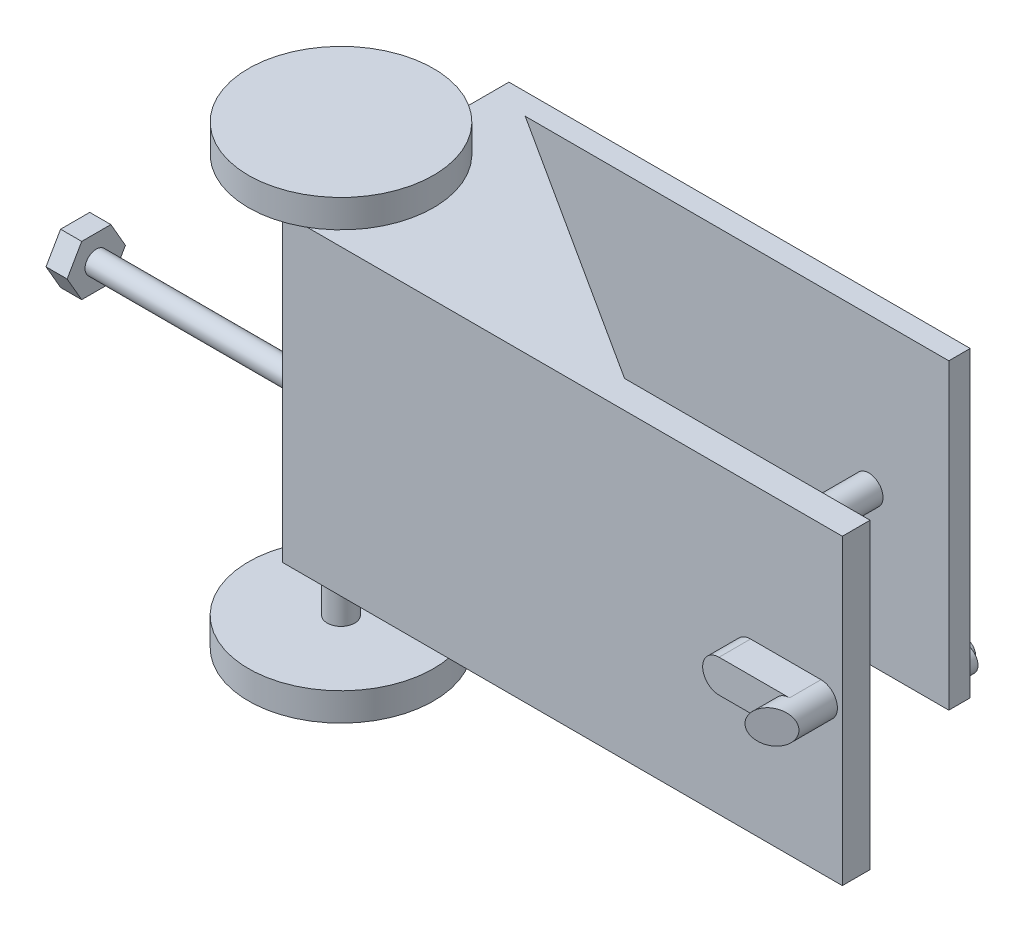
from build123d import *

# Parameters (mm, degrees)
ESQUISSE1_W              = 161.459359481
ESQUISSE1_H              = 87.247834422
BOSS_EXTRU_1_DEPTH       = 8
BOSS_EXTRU_4_DEPTH       = 8
BOSS_EXTRU_5_DEPTH       = 79.247834422
ESQUISSE10_W             = 66.113003305
ESQUISSE10_H             = 74.491262117
ENL_V_MAT_EXTRU_2_DEPTH  = 96
ESQUISSE13_W             = 6.170645308
ESQUISSE13_H             = 87.247834422
BOSS_EXTRU_6_DEPTH       = 133
ESQUISSE16_R             = 4.09250964
BOSS_EXTRU_8_DEPTH       = 61.090356673
BOSS_EXTRU_9_DEPTH       = 4.090356673
ESQUISSE20_R             = 2.950247855
BOSS_EXTRU_11_DEPTH      = 2.090356673
ESQUISSE22_R             = 2.950247855
BOSS_EXTRU_12_DEPTH      = 2.090356673
ESQUISSE23_R             = 3.399065534
BOSS_EXTRU_13_DEPTH      = 4.090356673
ESQUISSE24_R             = 3.959119082
BOSS_EXTRU_14_DEPTH      = 15.090356673
BOSS_EXTRU_14_DEPTH_BACK = 100
ESQUISSE25_R             = 26.684784867
BOSS_EXTRU_15_DEPTH      = 8.090356673
ESQUISSE26_R             = 26.684784865
BOSS_EXTRU_16_DEPTH      = 8.090356673
BOSS_EXTRU_17_DEPTH      = 9.090356673
ESQUISSE28_R             = 3.241314471
BOLT_DEPTH               = 58.090356673
ESQUISSE29_W             = 15.037271033
ESQUISSE29_H             = 95.331740118
ENL_V_MAT_EXTRU_4_DEPTH  = 9.090356673
BOLT_2_DEPTH             = 6.090356673
ESQUISSE31_R             = 4.734333437
BOSS_EXTRU_20_DEPTH      = 8.090356673
ENL_V_MAT_EXTRU_5_DEPTH  = 11.090356673
ESQUISSE34_W             = 0.427403847
ESQUISSE34_H             = 3.480288462
ESQUISSE34_W_2           = 0.427403846
ESQUISSE34_H_2           = 4.884615385
ENL_V_MAT_EXTRU_6_DEPTH  = 1.090356673


with BuildPart() as part:
    # Esquisse1 → Boss.-Extru.1 (new body)
    with BuildSketch(Plane.XY):
        with Locations((81.722874728, 43.623917211)):
            Rectangle(ESQUISSE1_W, ESQUISSE1_H)
    extrude(amount=BOSS_EXTRU_1_DEPTH)

    # Esquisse8 → Boss.-Extru.4 (add)
    with BuildSketch(Plane(origin=(0, 87.247834422, 0), x_dir=(1, 0, 0), z_dir=(0, 1, 0))):
        Polygon((0.993194987, 58.123224096), (0.993194987, 0), (91.655263297, 0), align=None)
    extrude(amount=-BOSS_EXTRU_4_DEPTH)

    # Esquisse9 → Boss.-Extru.5 (add)
    with BuildSketch(Plane(origin=(0, 79.247834422, 0), x_dir=(-1, 0, 0), z_dir=(0, -1, 0))):
        Polygon((-0.993194987, 58.123224096), (-91.655263297, 0), (-0.993194987, 0), align=None)
    extrude(amount=BOSS_EXTRU_5_DEPTH)

    # Esquisse10 → Enlèv. mat.-Extru.2 (cut)
    with BuildSketch(Plane.ZY.offset(-0.993194987)):
        with Locations((-33.027552153, 43.69715526)):
            Rectangle(ESQUISSE10_W, ESQUISSE10_H)
    extrude(amount=-ENL_V_MAT_EXTRU_2_DEPTH, mode=Mode.SUBTRACT)

    # Esquisse13 → Boss.-Extru.6 (add)
    with BuildSketch(Plane.ZY.offset(-0.993194987)):
        with Locations((-54.244008063, 43.623917211)):
            Rectangle(ESQUISSE13_W, ESQUISSE13_H)
    extrude(amount=-BOSS_EXTRU_6_DEPTH)

    # Esquisse16 → Boss.-Extru.8 (add)
    with BuildSketch(Plane(origin=(0, 0, -57.329330717), x_dir=(-1, 0, 0), z_dir=(0, 0, -1))):
        with Locations((-110.923599868, 43.623917211)):
            Circle(ESQUISSE16_R)
    extrude(amount=-BOSS_EXTRU_8_DEPTH)

    # Esquisse18 → Boss.-Extru.9 (add)
    with BuildSketch(Plane(origin=(0, 0, -57.329330717), x_dir=(-1, 0, 0), z_dir=(0, 0, -1))):
        with BuildLine():
            Line((-128.571488185, 8.728625509), (-108.086880087, 8.728625509))
            ThreePointArc((-108.086880087, 8.728625509), (-104.513983326, 5.155728748), (-108.086880087, 1.582831987))
            Line((-108.086880087, 1.582831987), (-128.571488185, 1.582831987))
            ThreePointArc((-128.571488185, 1.582831987), (-132.144384946, 5.155728748), (-128.571488185, 8.728625509))
        make_face()
    extrude(amount=BOSS_EXTRU_9_DEPTH)

    # Esquisse20 → Boss.-Extru.11 (add)
    with BuildSketch(Plane(origin=(0, 0, -61.41968739), x_dir=(-1, 0, 0), z_dir=(0, 0, -1))):
        with Locations((-126.423545035, 5.155728748)):
            Circle(ESQUISSE20_R)
    extrude(amount=BOSS_EXTRU_11_DEPTH)

    # Esquisse22 → Boss.-Extru.12 (add)
    with BuildSketch(Plane(origin=(0, 0, -61.41968739), x_dir=(-1, 0, 0), z_dir=(0, 0, -1))):
        with Locations((-119.402690218, 5.155728748)):
            Circle(ESQUISSE22_R)
    extrude(amount=BOSS_EXTRU_12_DEPTH)

    # Esquisse23 → Boss.-Extru.13 (add)
    with BuildSketch(Plane(origin=(0, 0, -61.41968739), x_dir=(-1, 0, 0), z_dir=(0, 0, -1))):
        with Locations((-109.574754959, 5.155728748)):
            Circle(ESQUISSE23_R)
    extrude(amount=BOSS_EXTRU_13_DEPTH)

    # Esquisse24 → Boss.-Extru.14 (add, two sides)
    with BuildSketch(Plane(origin=(0, 87.247834422, 0), x_dir=(1, 0, 0), z_dir=(0, 1, 0))) as boss_extru_14_sk:
        with Locations(Location((9.899824308, 0, 0), (0, 0, 270))):
            Circle(ESQUISSE24_R)
    extrude(amount=BOSS_EXTRU_14_DEPTH)
    extrude(boss_extru_14_sk.sketch, amount=-BOSS_EXTRU_14_DEPTH_BACK)

    # Esquisse25 → Boss.-Extru.15 (add)
    with BuildSketch(Plane(origin=(0, 102.338191096, 0), x_dir=(1, 0, 0), z_dir=(0, 1, 0))):
        with Locations(Location((9.899824308, 0, 0), (0, 0, 270))):
            Circle(ESQUISSE25_R)
    extrude(amount=BOSS_EXTRU_15_DEPTH)

    # Esquisse26 → Boss.-Extru.16 (add)
    with BuildSketch(Plane(origin=(0, -12.752165578, 0), x_dir=(-1, 0, 0), z_dir=(0, -1, 0))):
        with Locations(Location((-9.899824308, 0, 0), (0, 0, 270))):
            Circle(ESQUISSE26_R)
    extrude(amount=BOSS_EXTRU_16_DEPTH)

    # Esquisse27 → Boss.-Extru.17 (add)
    with BuildSketch(Plane.XY.offset(8)):
        with BuildLine():
            Line((156.30087893, 38.889583774), (135.997136687, 38.889583774))
            ThreePointArc((135.997136687, 38.889583774), (131.26280325, 43.623917211), (135.997136687, 48.358250648))
            Line((135.997136687, 48.358250648), (156.30087893, 48.358250648))
            ThreePointArc((156.30087893, 48.358250648), (161.035212367, 43.623917211), (156.30087893, 38.889583774))
        make_face()
    extrude(amount=BOSS_EXTRU_17_DEPTH)

    # Esquisse28 → bolt (add)
    with BuildSketch(Plane.ZY.offset(-0.993194987)):
        with Locations(Location((3.562327103, 43.697155259, 0), (0, 0, 180))):
            Circle(ESQUISSE28_R)
    extrude(amount=BOLT_DEPTH)

    # Esquisse29 → Enlèv. mat.-Extru.4 (cut)
    with BuildSketch(Plane(origin=(0, 0, -57.329330717), x_dir=(-1, 0, 0), z_dir=(0, 0, -1))):
        with Locations((-8.438121195, 39.581964363)):
            Rectangle(ESQUISSE29_W, ESQUISSE29_H)
    extrude(amount=ENL_V_MAT_EXTRU_4_DEPTH, mode=Mode.SUBTRACT)

    # Esquisse30 → bolt 2 (add)
    with BuildSketch(Plane.ZY.offset(57.097161686)):
        Polygon((11.970343142, 43.697155259), (7.766335123, 50.978710744), (-0.641680916, 50.978710744), (-4.845688936, 43.697155259), (-0.641680916, 36.415599774), (7.766335123, 36.415599774), align=None)
    extrude(amount=BOLT_2_DEPTH)

    # Esquisse31 → Boss.-Extru.20 (add)
    with BuildSketch(Plane.XY.offset(17.090356673)):
        with Locations(Location((156.30087893, 43.623917211, 0), (0, 0, 90))):
            Circle(ESQUISSE31_R)
    extrude(amount=BOSS_EXTRU_20_DEPTH)

    # Esquisse32 → Enlèv. mat.-Extru.5 (cut)
    with BuildSketch(Plane(origin=(0, 48.358250648, 0), x_dir=(1, 0, 0), z_dir=(0, 1, 0))):
        Polygon((151.566545494, -25.180713347), (161.035212367, -19.096120647), (164.647293985, -24.717137409), (155.178627112, -30.801730109), align=None)
    extrude(amount=-ENL_V_MAT_EXTRU_5_DEPTH, mode=Mode.SUBTRACT)

    # Esquisse34 → Enlèv. mat.-Extru.6 (cut)
    with BuildSketch(Plane(origin=(0, 0, -57.329330717), x_dir=(-1, 0, 0), z_dir=(0, 0, -1))):
        with BuildLine():
            Line((-35.621382075, 83.377609007), (-35.99536044, 83.091401074))
            add(Edge.make_bspline(
                [(-35.99536044, 83.091401074), (-36.022038452, 83.123195483), (-36.0750348, 83.186355644), (-36.160296072, 83.275046381), (-36.24915295, 83.358138754), (-36.341571469, 83.436028598), (-36.439215128, 83.505992125), (-36.539718572, 83.571675305), (-36.644763055, 83.630550334), (-36.790021665, 83.701937469), (-36.980042487, 83.776431344), (-37.219249036, 83.838892526), (-37.468955209, 83.878654198), (-37.639313372, 83.882960643), (-37.725964406, 83.885151074)],
                knots=[0, 0, 0, 0, 0.757959112, 1.505699292, 2.245454638, 2.979532153, 3.711538275, 4.438200793, 5.171680507, 5.909471876, 7.393775596, 8.890124382, 10.418191784, 12, 12, 12, 12], degree=3))
            add(Edge.make_bspline(
                [(-37.725964406, 83.885151074), (-37.773702753, 83.884601397), (-37.868736389, 83.883507143), (-38.009772348, 83.869071155), (-38.14817475, 83.848781258), (-38.283853566, 83.818675015), (-38.416636092, 83.780612273), (-38.547390396, 83.735129834), (-38.674223391, 83.678857713), (-38.798889636, 83.616661831), (-38.918332063, 83.546411629), (-39.031346253, 83.469785247), (-39.137520024, 83.387640155), (-39.236937364, 83.299668471), (-39.329699908, 83.206266375), (-39.415135498, 83.106438467), (-39.492948503, 83.000503902), (-39.564681312, 82.889859587), (-39.628924353, 82.774827806), (-39.682713224, 82.6549828), (-39.730345194, 82.532376859), (-39.76803595, 82.405624744), (-39.797868953, 82.275618338), (-39.81845338, 82.14200873), (-39.832725193, 82.005075044), (-39.833814005, 81.912261658), (-39.834362844, 81.865477096)],
                knots=[0, 0, 0, 0, 1.054917814, 2.100044995, 3.131103042, 4.146048494, 5.169673617, 6.183595914, 7.203665975, 8.234915748, 9.262203917, 10.264457458, 11.251630812, 12.227803204, 13.197192746, 14.159520551, 15.12972552, 16.100847026, 17.073214652, 18.039054194, 19.002613845, 19.979014051, 20.95965708, 21.949030935, 22.966165397, 24, 24, 24, 24], degree=3))
            add(Edge.make_bspline(
                [(-39.834362844, 81.865477096), (-39.832645869, 81.79508555), (-39.829274816, 81.656881086), (-39.799273333, 81.454446791), (-39.753682476, 81.260516874), (-39.685353423, 81.076303589), (-39.601099287, 80.89953543), (-39.494636169, 80.733203276), (-39.371332952, 80.574793594), (-39.22944526, 80.428050154), (-39.073771632, 80.294001121), (-38.906746795, 80.175958365), (-38.728786746, 80.077558472), (-38.541856403, 79.995676201), (-38.344517298, 79.932734011), (-38.137124299, 79.888423543), (-37.920128477, 79.859519005), (-37.771852258, 79.856751736), (-37.696389587, 79.855343382)],
                knots=[0, 0, 0, 0, 1.029171465, 2.020641659, 2.987623507, 3.938342917, 4.889210282, 5.84687017, 6.821220943, 7.821438502, 8.827599549, 9.822697543, 10.807740252, 11.797342354, 12.80366471, 13.83203677, 14.896651826, 16, 16, 16, 16], degree=3))
            add(Edge.make_bspline(
                [(-37.696389587, 79.855343382), (-37.613246285, 79.857641329), (-37.449600377, 79.862164238), (-37.209613884, 79.90048093), (-36.979876646, 79.962608311), (-36.760376305, 80.049555127), (-36.551731662, 80.162583251), (-36.353616206, 80.299604291), (-36.165862712, 80.46192163), (-36.052962503, 80.585859743), (-35.99536044, 80.649093382)],
                knots=[0, 0, 0, 0, 1.028121516, 2.023589091, 2.998037872, 3.967518031, 4.937445131, 5.927275754, 6.942489185, 8, 8, 8, 8], degree=3))
            Line((-35.99536044, 80.649093382), (-35.621382075, 80.365747529))
            add(Edge.make_bspline(
                [(-35.621382075, 80.365747529), (-35.651478503, 80.326914849), (-35.711527199, 80.249435497), (-35.808761143, 80.140208635), (-35.911192037, 80.037469215), (-36.0195807, 79.942045559), (-36.132680266, 79.852028233), (-36.25252152, 79.76997467), (-36.377529025, 79.694739574), (-36.507279226, 79.625850794), (-36.641634267, 79.564731254), (-36.780433159, 79.512406663), (-36.923077621, 79.467333153), (-37.069574173, 79.430251053), (-37.220226685, 79.401307186), (-37.374491509, 79.381958271), (-37.532701589, 79.368702309), (-37.639437952, 79.367494109), (-37.693527507, 79.366881844)],
                knots=[0, 0, 0, 0, 0.986787822, 1.968848986, 2.935600012, 3.899624008, 4.868462664, 5.837806735, 6.815139263, 7.798259679, 8.787526145, 9.778297419, 10.776456485, 11.791383307, 12.812564526, 13.85620153, 14.913611965, 16, 16, 16, 16], degree=3))
            add(Edge.make_bspline(
                [(-37.693527507, 79.366881844), (-37.744749783, 79.367238341), (-37.84603549, 79.367943269), (-37.995576291, 79.379362611), (-38.141158542, 79.394942432), (-38.282366158, 79.418401325), (-38.419969717, 79.446084159), (-38.552721798, 79.483192547), (-38.681928709, 79.524761235), (-38.807071344, 79.573617663), (-38.92825615, 79.628748611), (-39.045092265, 79.69105784), (-39.157525953, 79.760021377), (-39.266662615, 79.834119088), (-39.370890041, 79.915731059), (-39.471111446, 80.003723872), (-39.567888815, 80.097800951), (-39.627763897, 80.165639162), (-39.657867952, 80.199746928)],
                knots=[0, 0, 0, 0, 1.114604814, 2.203992996, 3.262667896, 4.300477797, 5.318619304, 6.316056647, 7.298880507, 8.271930387, 9.238335007, 10.195173496, 11.151986948, 12.108099108, 13.064862484, 14.031167946, 15.010108607, 16, 16, 16, 16], degree=3))
            add(Edge.make_bspline(
                [(-39.657867952, 80.199746928), (-39.706085738, 80.258994045), (-39.801939184, 80.376772998), (-39.924574489, 80.567662137), (-40.029550269, 80.766963521), (-40.114426076, 80.97572421), (-40.180778223, 81.193475762), (-40.226744778, 81.420327944), (-40.25661464, 81.656068894), (-40.260030426, 81.816411095), (-40.26176669, 81.897913995)],
                knots=[0, 0, 0, 0, 0.994628077, 1.977248131, 2.950237994, 3.925870899, 4.908910175, 5.911660606, 6.938484602, 8, 8, 8, 8], degree=3))
            add(Edge.make_bspline(
                [(-40.26176669, 81.897913995), (-40.259650516, 81.98357838), (-40.255487076, 82.152117709), (-40.220114225, 82.399460124), (-40.163210792, 82.636430421), (-40.082388597, 82.86258623), (-39.97991953, 83.079117076), (-39.853336887, 83.284368858), (-39.70411124, 83.479654218), (-39.533412943, 83.662010004), (-39.346223104, 83.828751052), (-39.14576429, 83.975444494), (-38.932428855, 84.097524399), (-38.708567064, 84.199572749), (-38.472502619, 84.278010393), (-38.224739177, 84.332919551), (-37.965742297, 84.36709677), (-37.789036639, 84.371417321), (-37.699251666, 84.373612613)],
                knots=[0, 0, 0, 0, 1.032925535, 2.032216505, 3.007276963, 3.968222605, 4.92396291, 5.891752235, 6.871517503, 7.883894988, 8.900124299, 9.891468569, 10.874487609, 11.85992873, 12.854644235, 13.869047385, 14.917252991, 16, 16, 16, 16], degree=3))
            add(Edge.make_bspline(
                [(-37.699251666, 84.373612613), (-37.64453126, 84.37295656), (-37.536217726, 84.371657971), (-37.375990009, 84.35899497), (-37.219994557, 84.337885385), (-37.0681239, 84.309152447), (-36.919639197, 84.27349177), (-36.775675298, 84.227036579), (-36.635387442, 84.173919013), (-36.499660399, 84.112743386), (-36.369145379, 84.04407257), (-36.243883031, 83.968667739), (-36.124868348, 83.886622375), (-36.01126388, 83.798634269), (-35.904970035, 83.702841943), (-35.802968881, 83.601880215), (-35.708724342, 83.492840975), (-35.650549459, 83.416089976), (-35.621382075, 83.377609007)],
                knots=[0, 0, 0, 0, 1.096760587, 2.17092713, 3.219439832, 4.250915756, 5.268269357, 6.278326846, 7.281116186, 8.274029601, 9.260640565, 10.235837813, 11.203064059, 12.156899882, 13.114053108, 14.069676657, 15.032185724, 16, 16, 16, 16], degree=3))
        make_face()
        with BuildLine():
            Line((-31.225228229, 82.96928569), (-31.225228229, 79.488997228))
            Line((-31.225228229, 79.488997228), (-31.652632075, 79.488997228))
            Line((-31.652632075, 79.488997228), (-31.652632075, 80.090987913))
            add(Edge.make_bspline(
                [(-31.652632075, 80.090987913), (-31.700826929, 80.036505466), (-31.794879793, 79.930182284), (-31.951962172, 79.791277614), (-32.1184703, 79.676462826), (-32.293596026, 79.583730263), (-32.477181207, 79.5140725), (-32.668818883, 79.464561334), (-32.868587226, 79.432729008), (-33.005002038, 79.42955035), (-33.074131474, 79.427939536)],
                knots=[0, 0, 0, 0, 1.074387032, 2.096679803, 3.090159297, 4.057316773, 5.018401886, 5.985159533, 6.978961417, 8, 8, 8, 8], degree=3))
            add(Edge.make_bspline(
                [(-33.074131474, 79.427939536), (-33.135592154, 79.429608278), (-33.256795336, 79.432899112), (-33.435088473, 79.458429246), (-33.606663998, 79.499428414), (-33.771684042, 79.556443553), (-33.929080783, 79.632073171), (-34.080201843, 79.722616797), (-34.224264327, 79.830440927), (-34.359072386, 79.953705351), (-34.483213072, 80.087592816), (-34.592153589, 80.230393721), (-34.682985459, 80.38149057), (-34.75894064, 80.538970326), (-34.81744638, 80.70404527), (-34.858231932, 80.876144559), (-34.883732326, 81.055064708), (-34.887021799, 81.176902417), (-34.888689767, 81.238681723)],
                knots=[0, 0, 0, 0, 1.033919861, 2.038935746, 3.024066025, 3.998881131, 4.97069526, 5.957263378, 6.95902576, 7.993208707, 9.027059324, 10.027763471, 11.009749337, 11.988697705, 12.965288445, 13.950418724, 14.960734635, 16, 16, 16, 16], degree=3))
            add(Edge.make_bspline(
                [(-34.888689767, 81.238681723), (-34.886984831, 81.29918412), (-34.883614264, 81.418794094), (-34.858504704, 81.594705465), (-34.816280368, 81.764139242), (-34.757024189, 81.926549939), (-34.681039243, 82.082134079), (-34.588608525, 82.231001699), (-34.479725359, 82.373562915), (-34.354196191, 82.506465548), (-34.218213521, 82.629230027), (-34.072741284, 82.735922335), (-33.921398176, 82.828065619), (-33.761836723, 82.901072671), (-33.596418626, 82.960140059), (-33.423671259, 83.001006348), (-33.244313361, 83.025087346), (-33.12254237, 83.028574536), (-33.060775104, 83.030343382)],
                knots=[0, 0, 0, 0, 1.020392517, 2.01726096, 2.990465484, 3.961182959, 4.928053699, 5.906110375, 6.912531644, 7.948652711, 8.985773172, 9.998621852, 10.987621588, 11.969261332, 12.953316658, 13.946091881, 14.958173133, 16, 16, 16, 16], degree=3))
            add(Edge.make_bspline(
                [(-33.060775104, 83.030343382), (-32.98974601, 83.028387013), (-32.850461309, 83.024550666), (-32.646724268, 82.992624597), (-32.453986603, 82.938687969), (-32.270760503, 82.865321659), (-32.097703926, 82.76782821), (-31.936455222, 82.644846906), (-31.785326833, 82.497153362), (-31.69772365, 82.383710007), (-31.652632075, 82.325317841)],
                knots=[0, 0, 0, 0, 1.038897134, 2.037228247, 3.008116434, 3.962042015, 4.918381754, 5.904844433, 6.921570401, 8, 8, 8, 8], degree=3))
            Line((-31.652632075, 82.325317841), (-31.652632075, 82.96928569))
            Line((-31.652632075, 82.96928569), (-31.225228229, 82.96928569))
        make_face()
        with BuildLine():
            add(Edge.make_bspline(
                [(-33.055050945, 82.602939536), (-33.11752724, 82.600716622), (-33.24084551, 82.596328943), (-33.421880385, 82.562075008), (-33.595117566, 82.505082042), (-33.759690617, 82.427137741), (-33.912999869, 82.32912721), (-34.050015185, 82.210579899), (-34.171857218, 82.074730248), (-34.274330249, 81.922191305), (-34.357865175, 81.758663259), (-34.416603172, 81.587724292), (-34.455341684, 81.412457519), (-34.459299349, 81.293581864), (-34.461285921, 81.233911591)],
                knots=[0, 0, 0, 0, 1.031046209, 2.035121221, 3.029706178, 4.034933723, 5.034054252, 6.02443088, 7.017295772, 8.038157696, 9.050218397, 10.03989886, 11.016116709, 12, 12, 12, 12], degree=3))
            add(Edge.make_bspline(
                [(-34.461285921, 81.233911591), (-34.458748334, 81.17459791), (-34.453683106, 81.056203036), (-34.417283054, 80.880697323), (-34.35621437, 80.709718073), (-34.27288142, 80.544716506), (-34.168532834, 80.391521713), (-34.047580775, 80.253082474), (-33.90885557, 80.134034142), (-33.755193498, 80.034378729), (-33.59108051, 79.953875442), (-33.418495768, 79.897860768), (-33.24068356, 79.861696002), (-33.11978092, 79.857471696), (-33.058867051, 79.855343382)],
                knots=[0, 0, 0, 0, 0.979072187, 1.954306742, 2.945804271, 3.96968567, 4.997920485, 5.998718438, 6.996577872, 8.005894225, 9.015743152, 10.005417472, 10.995077863, 12, 12, 12, 12], degree=3))
            add(Edge.make_bspline(
                [(-33.058867051, 79.855343382), (-32.997027345, 79.857602119), (-32.874034304, 79.862094522), (-32.692462348, 79.896495101), (-32.516256702, 79.953330501), (-32.347817652, 80.03211467), (-32.190905345, 80.129755929), (-32.050074305, 80.244065578), (-31.930990076, 80.377011697), (-31.830035132, 80.52312037), (-31.750875012, 80.683292765), (-31.693213303, 80.853836789), (-31.659122095, 81.034758379), (-31.654825327, 81.158398222), (-31.652632075, 81.221509247)],
                knots=[0, 0, 0, 0, 1.01762866, 2.023962475, 3.030623092, 4.058876274, 5.077231937, 6.066672613, 7.034107872, 8.005628644, 8.981990164, 9.965428785, 10.961468474, 12, 12, 12, 12], degree=3))
            add(Edge.make_bspline(
                [(-31.652632075, 81.221509247), (-31.653937893, 81.269593938), (-31.656508156, 81.364239826), (-31.676144038, 81.503206199), (-31.707379135, 81.636193876), (-31.75139303, 81.763342678), (-31.809211528, 81.883949609), (-31.878945095, 81.998880654), (-31.961820011, 82.10753806), (-32.056502179, 82.208425596), (-32.160141258, 82.300445889), (-32.269807401, 82.382584374), (-32.38679991, 82.450060525), (-32.509151307, 82.50590597), (-32.637073873, 82.550345741), (-32.771608538, 82.579992568), (-32.911325302, 82.60034929), (-33.00663797, 82.60206703), (-33.055050945, 82.602939536)],
                knots=[0, 0, 0, 0, 1.050140795, 2.067009409, 3.05949893, 4.030605086, 5.00011959, 5.97591094, 6.962425594, 7.979863591, 8.993523472, 9.986985069, 10.967611495, 11.937549037, 12.921786183, 13.919465291, 14.943216303, 16, 16, 16, 16], degree=3))
        make_face(mode=Mode.SUBTRACT)
        Polygon((-30.248305152, 84.373612613), (-29.820901305, 84.373612613), (-29.820901305, 81.549694344), (-28.236263385, 82.96928569), (-27.622824382, 82.96928569), (-29.46027931, 81.320727997), (-27.439651305, 79.488997228), (-28.053090308, 79.488997228), (-29.820901305, 81.092715678), (-29.820901305, 79.488997228), (-30.248305152, 79.488997228), align=None)
        with BuildLine():
            Line((-24.094834599, 80.58803569), (-23.715132075, 80.388644163))
            add(Edge.make_bspline(
                [(-23.715132075, 80.388644163), (-23.745389728, 80.334973059), (-23.804259138, 80.230550344), (-23.905497298, 80.087087705), (-24.011622225, 79.958027063), (-24.127424411, 79.846816355), (-24.249439224, 79.749863578), (-24.3783433, 79.665039609), (-24.514807727, 79.59276048), (-24.65883896, 79.531865076), (-24.811646564, 79.485043585), (-24.973600841, 79.451972485), (-25.145012055, 79.431530109), (-25.262504535, 79.429155471), (-25.32266663, 79.427939536)],
                knots=[0, 0, 0, 0, 1.120438281, 2.179929193, 3.190490725, 4.156257408, 5.095198341, 6.022838206, 6.959905092, 7.901321166, 8.864066838, 9.862729781, 10.905609505, 12, 12, 12, 12], degree=3))
            add(Edge.make_bspline(
                [(-25.32266663, 79.427939536), (-25.389534821, 79.429500514), (-25.519975289, 79.432545529), (-25.709849017, 79.458797061), (-25.888618868, 79.501621949), (-26.056274793, 79.56144649), (-26.212406215, 79.63958867), (-26.35732345, 79.734783536), (-26.491788591, 79.846542069), (-26.611564389, 79.975832301), (-26.719392673, 80.114192392), (-26.814541735, 80.258368078), (-26.894085596, 80.407996609), (-26.958791112, 80.562125429), (-27.011049161, 80.719783084), (-27.047470997, 80.882404045), (-27.068466476, 81.049548179), (-27.07168381, 81.162619911), (-27.073305152, 81.219601194)],
                knots=[0, 0, 0, 0, 1.145258523, 2.234067595, 3.276747158, 4.290159414, 5.277019952, 6.260822364, 7.254936242, 8.264827045, 9.274100331, 10.257902744, 11.220704747, 12.172965371, 13.118907548, 14.062713208, 15.023725156, 16, 16, 16, 16], degree=3))
            add(Edge.make_bspline(
                [(-27.073305152, 81.219601194), (-27.071863963, 81.273070232), (-27.069007717, 81.379038802), (-27.051004396, 81.535882275), (-27.019097968, 81.688320991), (-26.975315185, 81.836481615), (-26.91877581, 81.980116076), (-26.849607684, 82.119311791), (-26.767703055, 82.253920642), (-26.704467024, 82.338833477), (-26.672614046, 82.381605401)],
                knots=[0, 0, 0, 0, 1.024358464, 2.0301432, 3.019427413, 4.004406732, 4.986367066, 5.972626655, 6.978780325, 8, 8, 8, 8], degree=3))
            add(Edge.make_bspline(
                [(-26.672614046, 82.381605401), (-26.629468949, 82.433134114), (-26.544545482, 82.53455924), (-26.400913442, 82.667825319), (-26.245383532, 82.779463456), (-26.079904855, 82.872001737), (-25.902554152, 82.942314807), (-25.715715439, 82.994712624), (-25.517261266, 83.024074132), (-25.381590948, 83.028221363), (-25.312172339, 83.030343382)],
                knots=[0, 0, 0, 0, 1.030682036, 2.02871468, 2.997146059, 3.962720338, 4.930598197, 5.918074684, 6.934738563, 8, 8, 8, 8], degree=3))
            add(Edge.make_bspline(
                [(-25.312172339, 83.030343382), (-25.240806133, 83.028500908), (-25.100801906, 83.024886395), (-24.896651055, 82.991376991), (-24.70348308, 82.938237622), (-24.52137528, 82.863189072), (-24.350309191, 82.766361253), (-24.191396745, 82.64642539), (-24.041920222, 82.507063636), (-23.954958906, 82.399889412), (-23.910707495, 82.345352396)],
                knots=[0, 0, 0, 0, 1.056321875, 2.072262726, 3.055038591, 4.01806755, 4.982017516, 5.957941055, 6.960871419, 8, 8, 8, 8], degree=3))
            add(Edge.make_bspline(
                [(-23.910707495, 82.345352396), (-23.880599054, 82.304253952), (-23.820582583, 82.222330626), (-23.745407065, 82.08874773), (-23.680150752, 81.948987957), (-23.627990545, 81.80079216), (-23.585754652, 81.645916231), (-23.555197338, 81.483252983), (-23.53727725, 81.312850853), (-23.533754772, 81.19674579), (-23.531958998, 81.13755492)],
                knots=[0, 0, 0, 0, 0.94817472, 1.890038105, 2.849395472, 3.817997239, 4.812318967, 5.836947057, 6.897266129, 8, 8, 8, 8], degree=3))
            Line((-23.531958998, 81.13755492), (-26.645901305, 81.13755492))
            add(Edge.make_bspline(
                [(-26.645901305, 81.13755492), (-26.643806341, 81.091698217), (-26.639686678, 81.00152286), (-26.620480001, 80.86957333), (-26.590205777, 80.743879604), (-26.547657516, 80.625384465), (-26.496131559, 80.512540255), (-26.433013852, 80.406184055), (-26.35771253, 80.3068003), (-26.273721489, 80.213500017), (-26.180230763, 80.130413767), (-26.081874596, 80.056048314), (-25.977244424, 79.993719984), (-25.867165246, 79.943128777), (-25.751815067, 79.903523397), (-25.631157544, 79.87648897), (-25.505430107, 79.858381799), (-25.419724519, 79.856368398), (-25.376092111, 79.855343382)],
                knots=[0, 0, 0, 0, 1.094153842, 2.151609401, 3.174256925, 4.172055639, 5.149267565, 6.128595816, 7.11444997, 8.118368179, 9.117203808, 10.09244225, 11.054858984, 12.015122123, 12.976791628, 13.957293641, 14.960065497, 16, 16, 16, 16], degree=3))
            add(Edge.make_bspline(
                [(-25.376092111, 79.855343382), (-25.333432156, 79.856170773), (-25.248786623, 79.857812477), (-25.122728885, 79.873776255), (-24.998714028, 79.89958938), (-24.877255333, 79.93481826), (-24.760817861, 79.977785334), (-24.652987309, 80.029632436), (-24.553818158, 80.086986199), (-24.461130429, 80.152585792), (-24.371226684, 80.232879075), (-24.282042087, 80.333076253), (-24.18641564, 80.451577496), (-24.126558373, 80.54076642), (-24.094834599, 80.58803569)],
                knots=[0, 0, 0, 0, 0.99110716, 1.966546729, 2.947904876, 3.932708344, 4.903319531, 5.828989031, 6.710028674, 7.56322171, 8.463672341, 9.504779593, 10.677557249, 12, 12, 12, 12], degree=3))
        make_face()
        with BuildLine():
            add(Edge.make_bspline(
                [(-23.959362844, 81.564958767), (-23.975006465, 81.621650034), (-24.0051154, 81.730762475), (-24.068029882, 81.881857401), (-24.138884371, 82.016143438), (-24.222733942, 82.132592867), (-24.317737279, 82.236011933), (-24.427472331, 82.32638865), (-24.550529743, 82.407238825), (-24.686273431, 82.475482047), (-24.830021717, 82.533570748), (-24.980525143, 82.572521352), (-25.134092347, 82.599204336), (-25.237961501, 82.601689148), (-25.290229731, 82.602939536)],
                knots=[0, 0, 0, 0, 1.154881502, 2.222775134, 3.210006277, 4.132804581, 5.035138423, 5.962687519, 6.919655026, 7.923214229, 8.944639381, 9.960483929, 10.97369054, 12, 12, 12, 12], degree=3))
            add(Edge.make_bspline(
                [(-25.290229731, 82.602939536), (-25.33288736, 82.602107226), (-25.417212524, 82.600461923), (-25.541447191, 82.584854354), (-25.66075421, 82.559055423), (-25.776013905, 82.523724535), (-25.885715873, 82.476632115), (-25.992116611, 82.421409939), (-26.09251065, 82.353997998), (-26.15529577, 82.302618985), (-26.187014587, 82.276662493)],
                knots=[0, 0, 0, 0, 1.04873581, 2.073130211, 3.073294108, 4.04793562, 5.032784715, 6.005352987, 6.992311501, 8, 8, 8, 8], degree=3))
            add(Edge.make_bspline(
                [(-26.187014587, 82.276662493), (-26.209729374, 82.256123442), (-26.255698567, 82.214557408), (-26.31712192, 82.142944095), (-26.375932634, 82.065721434), (-26.429454498, 81.979935032), (-26.478545785, 81.886561758), (-26.524483468, 81.78638919), (-26.565830693, 81.67865718), (-26.589093614, 81.603583254), (-26.601062063, 81.564958767)],
                knots=[0, 0, 0, 0, 0.879870761, 1.780643979, 2.707998968, 3.669668524, 4.684282772, 5.740141944, 6.837334558, 8, 8, 8, 8], degree=3))
            Line((-26.601062063, 81.564958767), (-23.959362844, 81.564958767))
        make_face(mode=Mode.SUBTRACT)
        with BuildLine():
            add(Edge.make_bspline(
                [(-20.694684358, 84.434670305), (-20.668162247, 84.433440012), (-20.616226858, 84.431030862), (-20.54112459, 84.410400423), (-20.472739156, 84.375430494), (-20.412081598, 84.3285135), (-20.360031709, 84.273337293), (-20.323590814, 84.209028618), (-20.30016966, 84.139552399), (-20.297341341, 84.091090438), (-20.295901305, 84.066416098)],
                knots=[0, 0, 0, 0, 1.055194115, 2.066272739, 3.074728998, 4.095836921, 5.109056067, 6.073838105, 7.019297344, 8, 8, 8, 8], degree=3))
            add(Edge.make_bspline(
                [(-20.295901305, 84.066416098), (-20.297373816, 84.042382274), (-20.300284794, 83.994870247), (-20.323572723, 83.926598487), (-20.360342268, 83.863183373), (-20.412048221, 83.808114299), (-20.472748, 83.761223241), (-20.54112224, 83.726246436), (-20.616227476, 83.70561782), (-20.668162455, 83.703208419), (-20.694684358, 83.701977997)],
                knots=[0, 0, 0, 0, 0.96129708, 1.900370562, 2.859976407, 3.87933698, 4.906634145, 5.921202961, 6.938410037, 8, 8, 8, 8], degree=3))
            add(Edge.make_bspline(
                [(-20.694684358, 83.701977997), (-20.720902976, 83.703161438), (-20.771934089, 83.705464851), (-20.845911828, 83.726651196), (-20.913714165, 83.76123521), (-20.974490023, 83.807807269), (-21.025149679, 83.863521576), (-21.062022757, 83.926559786), (-21.085256902, 83.9948801), (-21.088175129, 84.042385584), (-21.089651305, 84.066416098)],
                knots=[0, 0, 0, 0, 1.054934014, 2.053291228, 3.073705704, 4.106921865, 5.123545215, 6.088680038, 7.033164197, 8, 8, 8, 8], degree=3))
            add(Edge.make_bspline(
                [(-21.089651305, 84.066416098), (-21.08820747, 84.091087004), (-21.085371685, 84.139542221), (-21.062005342, 84.209067962), (-21.025456817, 84.272996362), (-20.974456479, 84.328820346), (-20.913723092, 84.375418598), (-20.845909521, 84.409995683), (-20.771934698, 84.431183827), (-20.720903182, 84.433486992), (-20.694684358, 84.434670305)],
                knots=[0, 0, 0, 0, 0.98631895, 1.937192651, 2.907499808, 3.917963147, 4.944918757, 5.95915025, 6.951458133, 8, 8, 8, 8], degree=3))
        make_face()
        with Locations((-20.692776306, 81.229141459)):
            Rectangle(ESQUISSE34_W, ESQUISSE34_H)
        with BuildLine():
            Line((-17.792535921, 82.535203658), (-18.082559959, 82.236593382))
            add(Edge.make_bspline(
                [(-18.082559959, 82.236593382), (-18.10758418, 82.265594485), (-18.155827932, 82.321505197), (-18.232342912, 82.396258848), (-18.308575029, 82.45903804), (-18.383480736, 82.512040935), (-18.458943595, 82.552112809), (-18.534078045, 82.581361175), (-18.608961878, 82.599461132), (-18.659017162, 82.601793993), (-18.683596618, 82.602939536)],
                knots=[0, 0, 0, 0, 1.26578478, 2.440284043, 3.530471711, 4.527705817, 5.468200915, 6.346673037, 7.188140097, 8, 8, 8, 8], degree=3))
            add(Edge.make_bspline(
                [(-18.683596618, 82.602939536), (-18.713722002, 82.601476941), (-18.773004494, 82.598598761), (-18.857948197, 82.569869415), (-18.93680244, 82.525770381), (-19.00505176, 82.463220273), (-19.062865353, 82.391423178), (-19.105066112, 82.311146036), (-19.130873397, 82.224811377), (-19.13414555, 82.164899321), (-19.135805152, 82.134512553)],
                knots=[0, 0, 0, 0, 0.99966794, 1.967205029, 2.953328237, 3.988086729, 5.028030931, 6.008226631, 6.989793394, 8, 8, 8, 8], degree=3))
            add(Edge.make_bspline(
                [(-19.135805152, 82.134512553), (-19.134293654, 82.107009735), (-19.131274918, 82.052081631), (-19.107807115, 81.971053771), (-19.070433639, 81.892054729), (-19.035503839, 81.843663775), (-19.017505873, 81.8187298)],
                knots=[0, 0, 0, 0, 0.960159726, 1.917612774, 2.927026955, 4, 4, 4, 4], degree=3))
            add(Edge.make_bspline(
                [(-19.017505873, 81.8187298), (-19.006669833, 81.805415777), (-18.983606688, 81.777078555), (-18.940324387, 81.737748669), (-18.891308053, 81.694284392), (-18.832361995, 81.650827481), (-18.766025775, 81.605064312), (-18.690860892, 81.558797124), (-18.609252726, 81.508499103), (-18.55082732, 81.476597925), (-18.520458096, 81.460015858)],
                knots=[0, 0, 0, 0, 0.66740084, 1.420478572, 2.27185888, 3.217733974, 4.268547843, 5.408967954, 6.65319498, 8, 8, 8, 8], degree=3))
            add(Edge.make_bspline(
                [(-18.520458096, 81.460015858), (-18.483428193, 81.439271901), (-18.411898614, 81.399201406), (-18.310263098, 81.33700356), (-18.218024303, 81.275184372), (-18.134400698, 81.214404974), (-18.061001308, 81.152964822), (-17.995599185, 81.09321891), (-17.939825624, 81.03336203), (-17.908591888, 80.991543043), (-17.893662724, 80.971554319)],
                knots=[0, 0, 0, 0, 1.27191281, 2.456916733, 3.569705269, 4.599008579, 5.553216877, 6.436649441, 7.252746552, 8, 8, 8, 8], degree=3))
            add(Edge.make_bspline(
                [(-17.893662724, 80.971554319), (-17.868883399, 80.93118725), (-17.819567944, 80.850849289), (-17.767781517, 80.718562786), (-17.737763786, 80.578258852), (-17.733596979, 80.482284653), (-17.731478229, 80.433483406)],
                knots=[0, 0, 0, 0, 0.995354457, 1.980940102, 2.973342416, 4, 4, 4, 4], degree=3))
            add(Edge.make_bspline(
                [(-17.731478229, 80.433483406), (-17.732457309, 80.399099318), (-17.734386692, 80.331341716), (-17.747800705, 80.231553965), (-17.770871583, 80.136120871), (-17.802295584, 80.04400693), (-17.844728606, 79.956977087), (-17.894459716, 79.87283562), (-17.954160935, 79.793402657), (-18.022320985, 79.7187825), (-18.096950033, 79.650630108), (-18.176560171, 79.590726085), (-18.261249437, 79.540958862), (-18.350412692, 79.499776374), (-18.444252521, 79.467026352), (-18.542783597, 79.444353408), (-18.645692723, 79.430783329), (-18.715673998, 79.428899453), (-18.751332495, 79.427939536)],
                knots=[0, 0, 0, 0, 1.032770009, 2.035186124, 3.017557409, 3.978232242, 4.952395191, 5.920591857, 6.910227898, 7.931268572, 8.952309245, 9.941945286, 10.918353717, 11.897095711, 12.887975737, 13.898235213, 14.929059601, 16, 16, 16, 16], degree=3))
            add(Edge.make_bspline(
                [(-18.751332495, 79.427939536), (-18.799457116, 79.429290317), (-18.89503767, 79.431973111), (-19.036401895, 79.457154573), (-19.174542642, 79.496336877), (-19.308414531, 79.550378916), (-19.435023707, 79.618619708), (-19.550862572, 79.700347464), (-19.656333527, 79.792862425), (-19.716365892, 79.863773207), (-19.746382075, 79.899228598)],
                knots=[0, 0, 0, 0, 1.013940152, 2.01379169, 3.017749504, 4.037548394, 5.051665909, 6.043208538, 7.021604269, 8, 8, 8, 8], degree=3))
            Line((-19.746382075, 79.899228598), (-19.463036221, 80.221689536))
            add(Edge.make_bspline(
                [(-19.463036221, 80.221689536), (-19.436131617, 80.192631803), (-19.383972972, 80.136298993), (-19.300559531, 80.061290515), (-19.215678988, 79.998423786), (-19.130178933, 79.945841139), (-19.042793733, 79.905325323), (-18.954013094, 79.876861093), (-18.864017595, 79.858567389), (-18.80357176, 79.856419798), (-18.773275104, 79.855343382)],
                knots=[0, 0, 0, 0, 1.179806542, 2.287233372, 3.337373186, 4.324005949, 5.273901747, 6.200048787, 7.097828587, 8, 8, 8, 8], degree=3))
            add(Edge.make_bspline(
                [(-18.773275104, 79.855343382), (-18.732021069, 79.857208683), (-18.651417605, 79.860853168), (-18.53596949, 79.893941783), (-18.429373002, 79.945825753), (-18.336812664, 80.019419574), (-18.258024366, 80.105084121), (-18.2009721, 80.201577976), (-18.165217733, 80.306069209), (-18.161018571, 80.378503163), (-18.158882075, 80.415356904)],
                knots=[0, 0, 0, 0, 1.072336372, 2.095165389, 3.102688358, 4.141489647, 5.156069229, 6.117746104, 7.042326257, 8, 8, 8, 8], degree=3))
            add(Edge.make_bspline(
                [(-18.158882075, 80.415356904), (-18.160360211, 80.44571392), (-18.163278593, 80.505649787), (-18.186197474, 80.592395786), (-18.222409962, 80.6746772), (-18.258067002, 80.722832399), (-18.276227327, 80.747358106)],
                knots=[0, 0, 0, 0, 1.013901739, 2.00181326, 2.98231254, 4, 4, 4, 4], degree=3))
            add(Edge.make_bspline(
                [(-18.276227327, 80.747358106), (-18.287143514, 80.759652652), (-18.310922911, 80.786434614), (-18.354540936, 80.825113025), (-18.406767684, 80.866802724), (-18.468190548, 80.910796779), (-18.538933352, 80.956514881), (-18.619282817, 81.003717179), (-18.708138211, 81.05464562), (-18.770963249, 81.088418079), (-18.80380395, 81.106072048)],
                knots=[0, 0, 0, 0, 0.615000592, 1.339693406, 2.178160186, 3.116406724, 4.166410947, 5.330106347, 6.604359322, 8, 8, 8, 8], degree=3))
            add(Edge.make_bspline(
                [(-18.80380395, 81.106072048), (-18.839245985, 81.125855652), (-18.907979402, 81.164222374), (-19.005334823, 81.223979612), (-19.09316533, 81.284759011), (-19.173584326, 81.343151124), (-19.244560552, 81.402234623), (-19.305814396, 81.462075097), (-19.359757486, 81.520259221), (-19.389621642, 81.561485185), (-19.403886582, 81.581177216)],
                knots=[0, 0, 0, 0, 1.262093308, 2.447601706, 3.550203992, 4.582594899, 5.537233252, 6.418365656, 7.244515135, 8, 8, 8, 8], degree=3))
            add(Edge.make_bspline(
                [(-19.403886582, 81.581177216), (-19.428557148, 81.620836071), (-19.477906901, 81.700167639), (-19.525824715, 81.832579395), (-19.558762204, 81.971977848), (-19.561704599, 82.068162461), (-19.563208998, 82.117340077)],
                knots=[0, 0, 0, 0, 0.985009483, 1.970363186, 2.962279964, 4, 4, 4, 4], degree=3))
            add(Edge.make_bspline(
                [(-19.563208998, 82.117340077), (-19.562482111, 82.149487493), (-19.561059489, 82.212404542), (-19.549705619, 82.304849865), (-19.529034041, 82.39268146), (-19.503105735, 82.47721837), (-19.467069933, 82.556823005), (-19.424008898, 82.632556921), (-19.373407437, 82.704315438), (-19.315109959, 82.7709947), (-19.251011274, 82.831559176), (-19.181758034, 82.884353024), (-19.108907763, 82.929401314), (-19.032152021, 82.967181764), (-18.950753449, 82.995758646), (-18.865281016, 83.015431016), (-18.77590773, 83.028568988), (-18.714810127, 83.029743399), (-18.683596618, 83.030343382)],
                knots=[0, 0, 0, 0, 1.087655834, 2.128696564, 3.144119009, 4.137814668, 5.115653402, 6.093965665, 7.082169637, 8.081268856, 9.086088321, 10.061021666, 11.022561449, 11.980240094, 12.950172527, 13.934149372, 14.944599409, 16, 16, 16, 16], degree=3))
            add(Edge.make_bspline(
                [(-18.683596618, 83.030343382), (-18.646595989, 83.02884069), (-18.571900637, 83.025807117), (-18.459839521, 83.00171473), (-18.347943437, 82.962072899), (-18.235924879, 82.907322882), (-18.12460445, 82.83647474), (-18.013002941, 82.750845943), (-17.899780586, 82.650999839), (-17.829082888, 82.574664822), (-17.792535921, 82.535203658)],
                knots=[0, 0, 0, 0, 0.845714091, 1.707292901, 2.609013841, 3.555613372, 4.552488639, 5.621697636, 6.770543573, 8, 8, 8, 8], degree=3))
        make_face()
        with BuildLine():
            Line((-11.503593613, 82.96928569), (-11.503593613, 79.488997228))
            Line((-11.503593613, 79.488997228), (-11.930997459, 79.488997228))
            Line((-11.930997459, 79.488997228), (-11.930997459, 80.090987913))
            add(Edge.make_bspline(
                [(-11.930997459, 80.090987913), (-11.979192314, 80.036505466), (-12.073245178, 79.930182284), (-12.230327556, 79.791277614), (-12.396835684, 79.676462826), (-12.571961411, 79.583730263), (-12.755546592, 79.5140725), (-12.947184268, 79.464561334), (-13.146952611, 79.432729008), (-13.283367422, 79.42955035), (-13.352496858, 79.427939536)],
                knots=[0, 0, 0, 0, 1.074387032, 2.096679803, 3.090159297, 4.057316773, 5.018401886, 5.985159533, 6.978961417, 8, 8, 8, 8], degree=3))
            add(Edge.make_bspline(
                [(-13.352496858, 79.427939536), (-13.413957538, 79.429608278), (-13.535160721, 79.432899112), (-13.713453858, 79.458429246), (-13.885029383, 79.499428414), (-14.050049427, 79.556443553), (-14.207446167, 79.632073171), (-14.358567227, 79.722616797), (-14.502629712, 79.830440927), (-14.63743777, 79.953705351), (-14.761578457, 80.087592816), (-14.870518974, 80.230393721), (-14.961350843, 80.38149057), (-15.037306025, 80.538970326), (-15.095811765, 80.70404527), (-15.136597317, 80.876144559), (-15.162097711, 81.055064708), (-15.165387184, 81.176902417), (-15.167055152, 81.238681723)],
                knots=[0, 0, 0, 0, 1.033919861, 2.038935746, 3.024066025, 3.998881131, 4.97069526, 5.957263378, 6.95902576, 7.993208707, 9.027059324, 10.027763471, 11.009749337, 11.988697705, 12.965288445, 13.950418724, 14.960734635, 16, 16, 16, 16], degree=3))
            add(Edge.make_bspline(
                [(-15.167055152, 81.238681723), (-15.165350216, 81.29918412), (-15.161979649, 81.418794094), (-15.136870089, 81.594705465), (-15.094645752, 81.764139242), (-15.035389574, 81.926549939), (-14.959404628, 82.082134079), (-14.86697391, 82.231001699), (-14.758090744, 82.373562915), (-14.632561575, 82.506465548), (-14.496578906, 82.629230027), (-14.351106669, 82.735922335), (-14.199763561, 82.828065619), (-14.040202107, 82.901072671), (-13.874784011, 82.960140059), (-13.702036644, 83.001006348), (-13.522678746, 83.025087346), (-13.400907755, 83.028574536), (-13.339140488, 83.030343382)],
                knots=[0, 0, 0, 0, 1.020392517, 2.01726096, 2.990465484, 3.961182959, 4.928053699, 5.906110375, 6.912531644, 7.948652711, 8.985773172, 9.998621852, 10.987621588, 11.969261332, 12.953316658, 13.946091881, 14.958173133, 16, 16, 16, 16], degree=3))
            add(Edge.make_bspline(
                [(-13.339140488, 83.030343382), (-13.268111394, 83.028387013), (-13.128826693, 83.024550666), (-12.925089652, 82.992624597), (-12.732351988, 82.938687969), (-12.549125887, 82.865321659), (-12.376069311, 82.76782821), (-12.214820607, 82.644846906), (-12.063692217, 82.497153362), (-11.976089035, 82.383710007), (-11.930997459, 82.325317841)],
                knots=[0, 0, 0, 0, 1.038897134, 2.037228247, 3.008116434, 3.962042015, 4.918381754, 5.904844433, 6.921570401, 8, 8, 8, 8], degree=3))
            Line((-11.930997459, 82.325317841), (-11.930997459, 82.96928569))
            Line((-11.930997459, 82.96928569), (-11.503593613, 82.96928569))
        make_face()
        with BuildLine():
            add(Edge.make_bspline(
                [(-13.33341633, 82.602939536), (-13.395892625, 82.600716622), (-13.519210895, 82.596328943), (-13.700245769, 82.562075008), (-13.87348295, 82.505082042), (-14.038056002, 82.427137741), (-14.191365253, 82.32912721), (-14.32838057, 82.210579899), (-14.450222603, 82.074730248), (-14.552695634, 81.922191305), (-14.63623056, 81.758663259), (-14.694968557, 81.587724292), (-14.733707069, 81.412457519), (-14.737664734, 81.293581864), (-14.739651305, 81.233911591)],
                knots=[0, 0, 0, 0, 1.031046209, 2.035121221, 3.029706178, 4.034933723, 5.034054252, 6.02443088, 7.017295772, 8.038157696, 9.050218397, 10.03989886, 11.016116709, 12, 12, 12, 12], degree=3))
            add(Edge.make_bspline(
                [(-14.739651305, 81.233911591), (-14.737113719, 81.17459791), (-14.732048491, 81.056203036), (-14.695648439, 80.880697323), (-14.634579754, 80.709718073), (-14.551246804, 80.544716506), (-14.446898219, 80.391521713), (-14.325946159, 80.253082474), (-14.187220955, 80.134034142), (-14.033558883, 80.034378729), (-13.869445895, 79.953875442), (-13.696861152, 79.897860768), (-13.519048945, 79.861696002), (-13.398146305, 79.857471696), (-13.337232435, 79.855343382)],
                knots=[0, 0, 0, 0, 0.979072187, 1.954306742, 2.945804271, 3.96968567, 4.997920485, 5.998718438, 6.996577872, 8.005894225, 9.015743152, 10.005417472, 10.995077863, 12, 12, 12, 12], degree=3))
            add(Edge.make_bspline(
                [(-13.337232435, 79.855343382), (-13.27539273, 79.857602119), (-13.152399689, 79.862094522), (-12.970827733, 79.896495101), (-12.794622087, 79.953330501), (-12.626183037, 80.03211467), (-12.46927073, 80.129755929), (-12.328439689, 80.244065578), (-12.209355461, 80.377011697), (-12.108400517, 80.52312037), (-12.029240397, 80.683292765), (-11.971578687, 80.853836789), (-11.93748748, 81.034758379), (-11.933190712, 81.158398222), (-11.930997459, 81.221509247)],
                knots=[0, 0, 0, 0, 1.01762866, 2.023962475, 3.030623092, 4.058876274, 5.077231937, 6.066672613, 7.034107872, 8.005628644, 8.981990164, 9.965428785, 10.961468474, 12, 12, 12, 12], degree=3))
            add(Edge.make_bspline(
                [(-11.930997459, 81.221509247), (-11.932303277, 81.269593938), (-11.934873541, 81.364239826), (-11.954509423, 81.503206199), (-11.985744519, 81.636193876), (-12.029758415, 81.763342678), (-12.087576913, 81.883949609), (-12.15731048, 81.998880654), (-12.240185395, 82.10753806), (-12.334867564, 82.208425596), (-12.438506643, 82.300445889), (-12.548172786, 82.382584374), (-12.665165295, 82.450060525), (-12.787516692, 82.50590597), (-12.915439258, 82.550345741), (-13.049973922, 82.579992568), (-13.189690687, 82.60034929), (-13.285003355, 82.60206703), (-13.33341633, 82.602939536)],
                knots=[0, 0, 0, 0, 1.050140795, 2.067009409, 3.05949893, 4.030605086, 5.00011959, 5.97591094, 6.962425594, 7.979863591, 8.993523472, 9.986985069, 10.967611495, 11.937549037, 12.921786183, 13.919465291, 14.943216303, 16, 16, 16, 16], degree=3))
        make_face(mode=Mode.SUBTRACT)
        with Locations((-8.542295536, 81.93130492)):
            Rectangle(ESQUISSE34_W_2, ESQUISSE34_H_2)
        with BuildLine():
            add(Edge.make_bspline(
                [(-7.200934358, 84.434670305), (-7.174412247, 84.433440012), (-7.122476858, 84.431030862), (-7.04737459, 84.410400423), (-6.978989156, 84.375430494), (-6.918331598, 84.3285135), (-6.866281709, 84.273337293), (-6.829840814, 84.209028618), (-6.80641966, 84.139552399), (-6.803591341, 84.091090438), (-6.802151305, 84.066416098)],
                knots=[0, 0, 0, 0, 1.055194115, 2.066272739, 3.074728998, 4.095836921, 5.109056067, 6.073838105, 7.019297344, 8, 8, 8, 8], degree=3))
            add(Edge.make_bspline(
                [(-6.802151305, 84.066416098), (-6.803623816, 84.042382274), (-6.806534794, 83.994870247), (-6.829822723, 83.926598487), (-6.866592268, 83.863183373), (-6.918298221, 83.808114299), (-6.978998, 83.761223241), (-7.04737224, 83.726246436), (-7.122477476, 83.70561782), (-7.174412455, 83.703208419), (-7.200934358, 83.701977997)],
                knots=[0, 0, 0, 0, 0.96129708, 1.900370562, 2.859976407, 3.87933698, 4.906634145, 5.921202961, 6.938410037, 8, 8, 8, 8], degree=3))
            add(Edge.make_bspline(
                [(-7.200934358, 83.701977997), (-7.227152976, 83.703161438), (-7.278184089, 83.705464851), (-7.352161828, 83.726651196), (-7.419964165, 83.76123521), (-7.480740023, 83.807807269), (-7.531399679, 83.863521576), (-7.568272757, 83.926559786), (-7.591506902, 83.9948801), (-7.594425129, 84.042385584), (-7.595901305, 84.066416098)],
                knots=[0, 0, 0, 0, 1.054934014, 2.053291228, 3.073705704, 4.106921865, 5.123545215, 6.088680038, 7.033164197, 8, 8, 8, 8], degree=3))
            add(Edge.make_bspline(
                [(-7.595901305, 84.066416098), (-7.59445747, 84.091087004), (-7.591621685, 84.139542221), (-7.568255342, 84.209067962), (-7.531706817, 84.272996362), (-7.480706479, 84.328820346), (-7.419973092, 84.375418598), (-7.352159521, 84.409995683), (-7.278184698, 84.431183827), (-7.227153182, 84.433486992), (-7.200934358, 84.434670305)],
                knots=[0, 0, 0, 0, 0.98631895, 1.937192651, 2.907499808, 3.917963147, 4.944918757, 5.95915025, 6.951458133, 8, 8, 8, 8], degree=3))
        make_face()
        with Locations((-7.199026306, 81.229141459)):
            Rectangle(ESQUISSE34_W, ESQUISSE34_H)
        with BuildLine():
            Line((-3.090988445, 80.58803569), (-2.711285921, 80.388644163))
            add(Edge.make_bspline(
                [(-2.711285921, 80.388644163), (-2.741543574, 80.334973059), (-2.800412984, 80.230550344), (-2.901651144, 80.087087705), (-3.007776072, 79.958027063), (-3.123578257, 79.846816355), (-3.24559307, 79.749863578), (-3.374497147, 79.665039609), (-3.510961574, 79.59276048), (-3.654992806, 79.531865076), (-3.80780041, 79.485043585), (-3.969754687, 79.451972485), (-4.141165901, 79.431530109), (-4.258658381, 79.429155471), (-4.318820476, 79.427939536)],
                knots=[0, 0, 0, 0, 1.120438281, 2.179929193, 3.190490725, 4.156257408, 5.095198341, 6.022838206, 6.959905092, 7.901321166, 8.864066838, 9.862729781, 10.905609505, 12, 12, 12, 12], degree=3))
            add(Edge.make_bspline(
                [(-4.318820476, 79.427939536), (-4.385688667, 79.429500514), (-4.516129136, 79.432545529), (-4.706002863, 79.458797061), (-4.884772714, 79.501621949), (-5.052428639, 79.56144649), (-5.208560062, 79.63958867), (-5.353477296, 79.734783536), (-5.487942437, 79.846542069), (-5.607718236, 79.975832301), (-5.715546519, 80.114192392), (-5.810695581, 80.258368078), (-5.890239443, 80.407996609), (-5.954944959, 80.562125429), (-6.007203007, 80.719783084), (-6.043624843, 80.882404045), (-6.064620322, 81.049548179), (-6.067837657, 81.162619911), (-6.069458998, 81.219601194)],
                knots=[0, 0, 0, 0, 1.145258523, 2.234067595, 3.276747158, 4.290159414, 5.277019952, 6.260822364, 7.254936242, 8.264827045, 9.274100331, 10.257902744, 11.220704747, 12.172965371, 13.118907548, 14.062713208, 15.023725156, 16, 16, 16, 16], degree=3))
            add(Edge.make_bspline(
                [(-6.069458998, 81.219601194), (-6.068017809, 81.273070232), (-6.065161563, 81.379038802), (-6.047158242, 81.535882275), (-6.015251815, 81.688320991), (-5.971469031, 81.836481615), (-5.914929657, 81.980116076), (-5.84576153, 82.119311791), (-5.763856901, 82.253920642), (-5.70062087, 82.338833477), (-5.668767892, 82.381605401)],
                knots=[0, 0, 0, 0, 1.024358464, 2.0301432, 3.019427413, 4.004406732, 4.986367066, 5.972626655, 6.978780325, 8, 8, 8, 8], degree=3))
            add(Edge.make_bspline(
                [(-5.668767892, 82.381605401), (-5.625622795, 82.433134114), (-5.540699328, 82.53455924), (-5.397067288, 82.667825319), (-5.241537378, 82.779463456), (-5.076058701, 82.872001737), (-4.898707999, 82.942314807), (-4.711869285, 82.994712624), (-4.513415112, 83.024074132), (-4.377744794, 83.028221363), (-4.308326185, 83.030343382)],
                knots=[0, 0, 0, 0, 1.030682036, 2.02871468, 2.997146059, 3.962720338, 4.930598197, 5.918074684, 6.934738563, 8, 8, 8, 8], degree=3))
            add(Edge.make_bspline(
                [(-4.308326185, 83.030343382), (-4.23695998, 83.028500908), (-4.096955752, 83.024886395), (-3.892804902, 82.991376991), (-3.699636927, 82.938237622), (-3.517529126, 82.863189072), (-3.346463037, 82.766361253), (-3.187550591, 82.64642539), (-3.038074069, 82.507063636), (-2.951112752, 82.399889412), (-2.906861342, 82.345352396)],
                knots=[0, 0, 0, 0, 1.056321875, 2.072262726, 3.055038591, 4.01806755, 4.982017516, 5.957941055, 6.960871419, 8, 8, 8, 8], degree=3))
            add(Edge.make_bspline(
                [(-2.906861342, 82.345352396), (-2.8767529, 82.304253952), (-2.816736429, 82.222330626), (-2.741560911, 82.08874773), (-2.676304598, 81.948987957), (-2.624144391, 81.80079216), (-2.581908498, 81.645916231), (-2.551351184, 81.483252983), (-2.533431096, 81.312850853), (-2.529908618, 81.19674579), (-2.528112844, 81.13755492)],
                knots=[0, 0, 0, 0, 0.94817472, 1.890038105, 2.849395472, 3.817997239, 4.812318967, 5.836947057, 6.897266129, 8, 8, 8, 8], degree=3))
            Line((-2.528112844, 81.13755492), (-5.642055152, 81.13755492))
            add(Edge.make_bspline(
                [(-5.642055152, 81.13755492), (-5.639960187, 81.091698217), (-5.635840524, 81.00152286), (-5.616633847, 80.86957333), (-5.586359623, 80.743879604), (-5.543811363, 80.625384465), (-5.492285405, 80.512540255), (-5.429167698, 80.406184055), (-5.353866376, 80.3068003), (-5.269875335, 80.213500017), (-5.176384609, 80.130413767), (-5.078028442, 80.056048314), (-4.97339827, 79.993719984), (-4.863319092, 79.943128777), (-4.747968913, 79.903523397), (-4.62731139, 79.87648897), (-4.501583953, 79.858381799), (-4.415878365, 79.856368398), (-4.372245957, 79.855343382)],
                knots=[0, 0, 0, 0, 1.094153842, 2.151609401, 3.174256925, 4.172055639, 5.149267565, 6.128595816, 7.11444997, 8.118368179, 9.117203808, 10.09244225, 11.054858984, 12.015122123, 12.976791628, 13.957293641, 14.960065497, 16, 16, 16, 16], degree=3))
            add(Edge.make_bspline(
                [(-4.372245957, 79.855343382), (-4.329586003, 79.856170773), (-4.244940469, 79.857812477), (-4.118882731, 79.873776255), (-3.994867875, 79.89958938), (-3.873409179, 79.93481826), (-3.756971707, 79.977785334), (-3.649141155, 80.029632436), (-3.549972004, 80.086986199), (-3.457284275, 80.152585792), (-3.36738053, 80.232879075), (-3.278195933, 80.333076253), (-3.182569487, 80.451577496), (-3.122712219, 80.54076642), (-3.090988445, 80.58803569)],
                knots=[0, 0, 0, 0, 0.99110716, 1.966546729, 2.947904876, 3.932708344, 4.903319531, 5.828989031, 6.710028674, 7.56322171, 8.463672341, 9.504779593, 10.677557249, 12, 12, 12, 12], degree=3))
        make_face()
        with BuildLine():
            add(Edge.make_bspline(
                [(-2.95551669, 81.564958767), (-2.971160311, 81.621650034), (-3.001269247, 81.730762475), (-3.064183728, 81.881857401), (-3.135038218, 82.016143438), (-3.218887788, 82.132592867), (-3.313891125, 82.236011933), (-3.423626177, 82.32638865), (-3.546683589, 82.407238825), (-3.682427277, 82.475482047), (-3.826175563, 82.533570748), (-3.976678989, 82.572521352), (-4.130246193, 82.599204336), (-4.234115347, 82.601689148), (-4.286383577, 82.602939536)],
                knots=[0, 0, 0, 0, 1.154881502, 2.222775134, 3.210006277, 4.132804581, 5.035138423, 5.962687519, 6.919655026, 7.923214229, 8.944639381, 9.960483929, 10.97369054, 12, 12, 12, 12], degree=3))
            add(Edge.make_bspline(
                [(-4.286383577, 82.602939536), (-4.329041206, 82.602107226), (-4.41336637, 82.600461923), (-4.537601038, 82.584854354), (-4.656908057, 82.559055423), (-4.772167751, 82.523724535), (-4.881869719, 82.476632115), (-4.988270457, 82.421409939), (-5.088664496, 82.353997998), (-5.151449616, 82.302618985), (-5.183168433, 82.276662493)],
                knots=[0, 0, 0, 0, 1.04873581, 2.073130211, 3.073294108, 4.04793562, 5.032784715, 6.005352987, 6.992311501, 8, 8, 8, 8], degree=3))
            add(Edge.make_bspline(
                [(-5.183168433, 82.276662493), (-5.20588322, 82.256123442), (-5.251852413, 82.214557408), (-5.313275766, 82.142944095), (-5.372086481, 82.065721434), (-5.425608344, 81.979935032), (-5.474699631, 81.886561758), (-5.520637314, 81.78638919), (-5.561984539, 81.67865718), (-5.58524746, 81.603583254), (-5.597215909, 81.564958767)],
                knots=[0, 0, 0, 0, 0.879870761, 1.780643979, 2.707998968, 3.669668524, 4.684282772, 5.740141944, 6.837334558, 8, 8, 8, 8], degree=3))
            Line((-5.597215909, 81.564958767), (-2.95551669, 81.564958767))
        make_face(mode=Mode.SUBTRACT)
    extrude(amount=-ENL_V_MAT_EXTRU_6_DEPTH, mode=Mode.SUBTRACT)


solid = part.part
